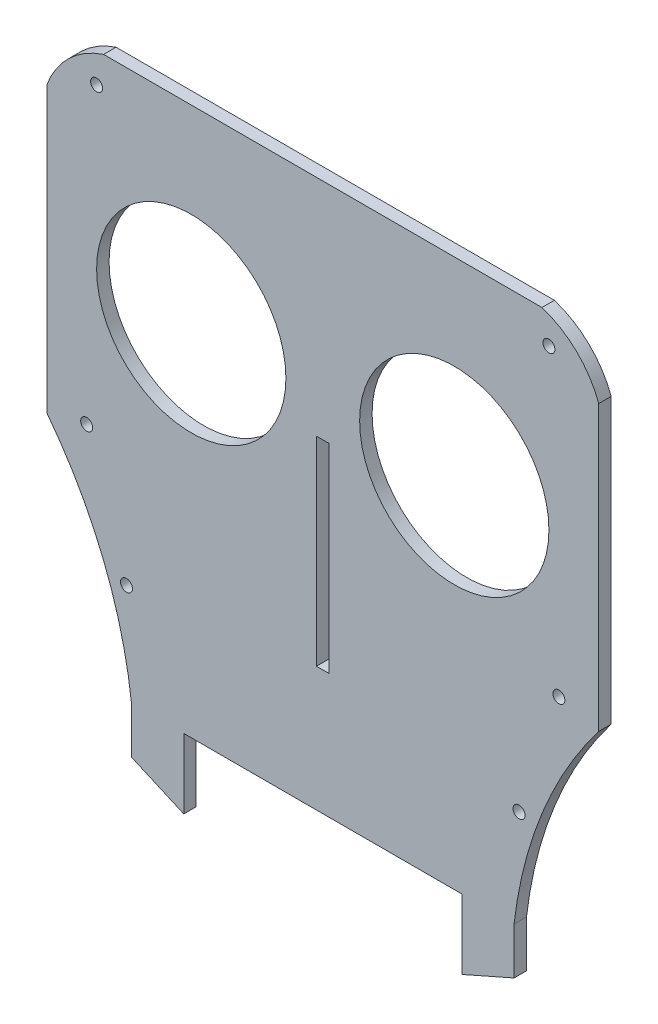
from build123d import *

# Parameters (mm, degrees)
SKETCH1_W                           = 140.716
SKETCH1_H                           = 139.7
MAIN_BODY_DEPTH                     = 3.175
SKETCH2_R                           = 24.13
CUTS_FOR_EYES_AND_MOTORS_DEPTH      = 4.175
SKETCH4_W                           = 3.2258
SKETCH4_H                           = 50.8
CUT_FOR_NOSE_DEPTH                  = 4.175
CUT_FOR_ROUNDED_FACE_FEATURES_DEPTH = 4.175
SKETCH12_R                          = 1.524
HOLES_FOR_SPACERS_DEPTH             = 4.175
BOSS_EXTRUDE1_DEPTH                 = 3.175


with BuildPart() as part:
    # Sketch1 → main body (new body)
    with BuildSketch(Plane.XY):
        with Locations((0, -69.85)):
            Rectangle(SKETCH1_W, SKETCH1_H)
    extrude(amount=MAIN_BODY_DEPTH)

    # Sketch2 → cuts for eyes and motors (cut, through all)
    with BuildSketch(Plane.XY.offset(3.175)):
        with Locations((-33.528, -48.26)):
            Circle(SKETCH2_R)
    cuts_for_eyes_and_motors = extrude(amount=-CUTS_FOR_EYES_AND_MOTORS_DEPTH, mode=Mode.SUBTRACT)

    # Sketch4 → cut for nose (cut, through all)
    with BuildSketch(Plane.XY.offset(3.175)):
        with Locations((0, -82.55)):
            Rectangle(SKETCH4_W, SKETCH4_H)
    extrude(amount=-CUT_FOR_NOSE_DEPTH, mode=Mode.SUBTRACT)

    # Mirror1: cuts for eyes and motors across plane
    add(cuts_for_eyes_and_motors.mirror(Plane(origin=(0, 0, 0), x_dir=(0, 0, 1), z_dir=(1, 0, 0))), mode=Mode.SUBTRACT)

    # Sketch11 → cut for rounded face features (cut, through all)
    with BuildSketch(Plane.XY.offset(3.175)):
        with BuildLine():
            Line((-70.358, -139.7), (-70.358, -86.36))
            ThreePointArc((-70.358, -86.36), (-55.943359781, -111.56490753), (-48.768, -139.7))
            Line((-48.768, -139.7), (-70.358, -139.7))
        make_face()
        with BuildLine():
            Line((-70.358, 0), (-70.358, -13.97))
            ThreePointArc((-70.358, -13.97), (-64.724440046, -5.321180316), (-55.88, 0))
            Line((-55.88, 0), (-70.358, 0))
        make_face()
    cut_for_rounded_face_features = extrude(amount=-CUT_FOR_ROUNDED_FACE_FEATURES_DEPTH, mode=Mode.SUBTRACT)

    # mirror of rounded feature: cut for rounded face features across plane
    add(cut_for_rounded_face_features.mirror(Plane(origin=(0, 0, 0), x_dir=(0, 0, 1), z_dir=(1, 0, 0))), mode=Mode.SUBTRACT)

    # Sketch12 → holes for spacers (cut, through all)
    with BuildSketch(Plane.XY.offset(3.175)):
        with Locations((-57.658, -7.62)):
            Circle(SKETCH12_R)
        with Locations((-60.198, -83.82)):
            Circle(SKETCH12_R)
        with Locations((-50.038, -114.3)):
            Circle(SKETCH12_R)
    holes_for_spacers = extrude(amount=-HOLES_FOR_SPACERS_DEPTH, mode=Mode.SUBTRACT)

    # mirror of spacer hole: holes for spacers across plane
    add(holes_for_spacers.mirror(Plane(origin=(0, 0, 0), x_dir=(0, 0, 1), z_dir=(1, 0, 0))), mode=Mode.SUBTRACT)

    # Sketch14 → Boss-Extrude1 (add)
    with BuildSketch(Plane.XY.offset(3.175)):
        Polygon((-48.768, -139.7), (-35.433, -139.7), (-35.433, -157.48), (-48.768, -151.596070028), align=None)
    boss_extrude1 = extrude(amount=-BOSS_EXTRUDE1_DEPTH)

    # Mirror3: Boss-Extrude1 across plane
    add(boss_extrude1.mirror(Plane(origin=(0, 0, 0), x_dir=(0, 0, 1), z_dir=(1, 0, 0))))


solid = part.part
